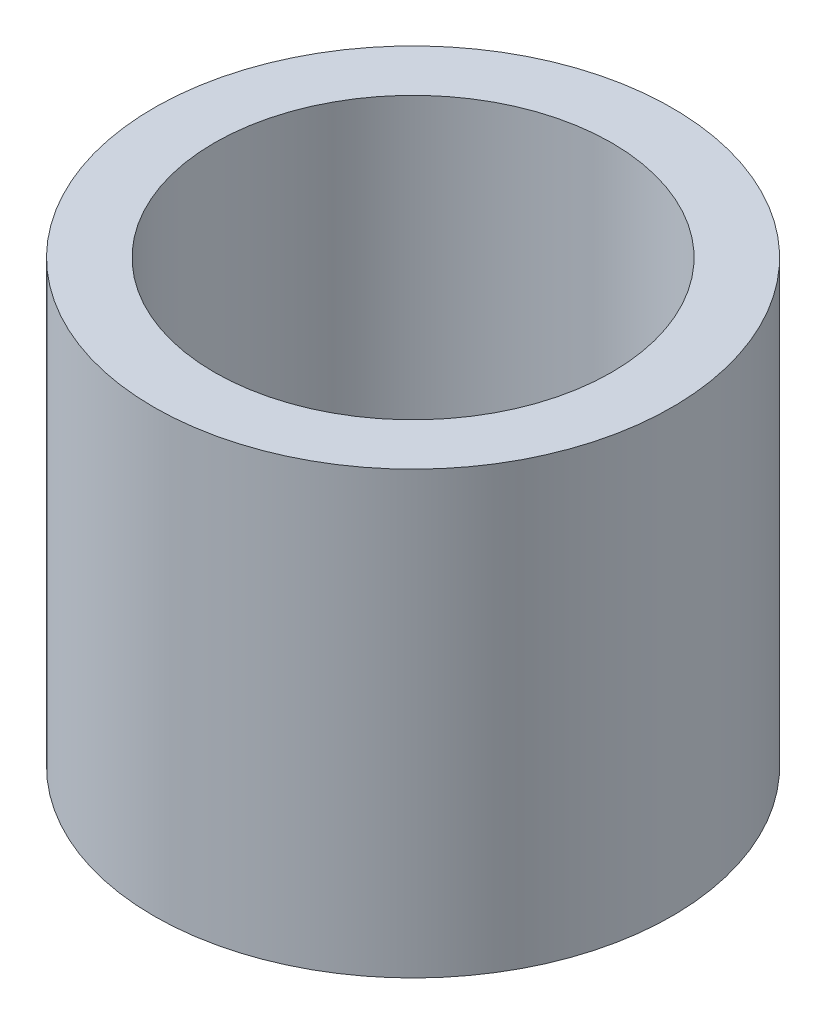
from build123d import *

# Parameters (mm, degrees)
SKETCH1_R      = 4.572
SKETCH1_R_2    = 3.5052
EXTRUDE1_DEPTH = 7.7724


with BuildPart() as part:
    # Sketch1 → Extrude1 (new body)
    with BuildSketch(Plane(origin=(0, 0, 0), x_dir=(1, 0, 0), z_dir=(0, 1, 0))):
        with Locations(Location((0, 0, 0), (0, 0, 270))):  # turned: the seam where the file's is
            Circle(SKETCH1_R)
        with Locations(Location((0, 0, 0), (0, 0, 270))):  # turned: the seam where the file's is
            Circle(SKETCH1_R_2, mode=Mode.SUBTRACT)
    extrude(amount=EXTRUDE1_DEPTH)


solid = part.part
